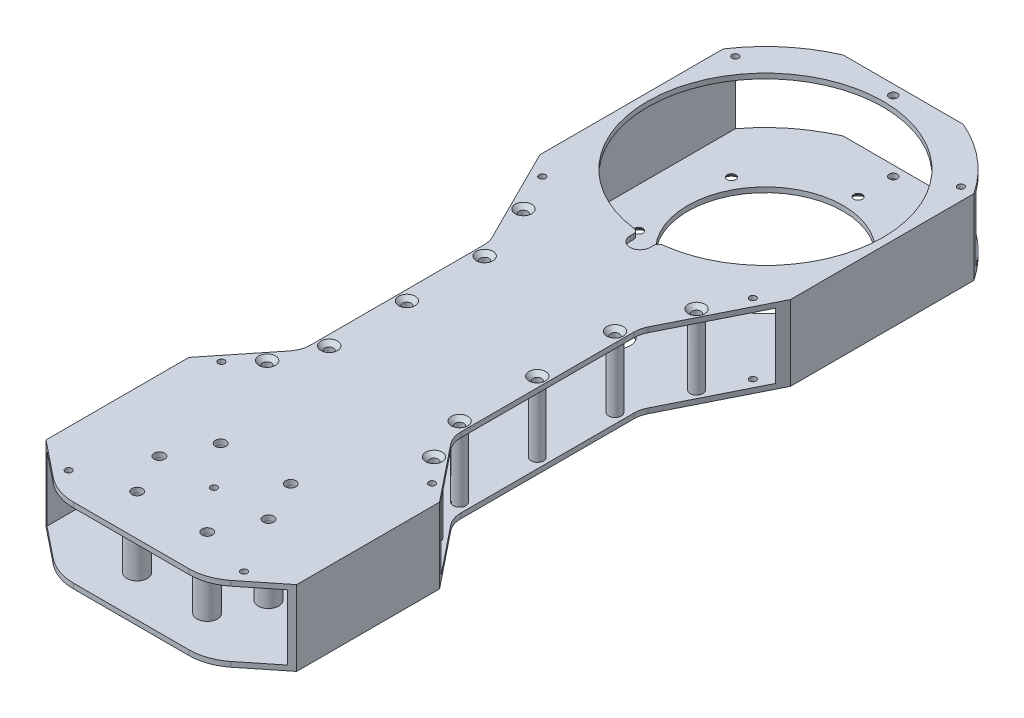
from build123d import *

# Parameters (mm, degrees)
SKETCH_1_W                   = 100
SKETCH_1_H                   = 30
SKETCH_1_W_2                 = 96
SKETCH_1_H_2                 = 26
EXTRUDE_1_DEPTH              = 315
CUT_EXTRUDE_1_REACH          = 32
SKETCH_2_R                   = 5
CUT_EXTRUDE_2_REACH          = 32
SKETCH_3_R                   = 47
SKETCH_8_R                   = 2.1
CUT_EXTRUDE_7_DEPTH          = 31
CUT_EXTRUDE_8_REACH          = 32
SKETCH_9_R                   = 1.6
CUT_EXTRUDE_4_DEPTH          = 31
CUT_EXTRUDE_5_DEPTH          = 31
FILLET_1_R                   = 10
SKETCH_10_R                  = 1.6
CUT_EXTRUDE_9_DEPTH          = 31
SKETCH_11_R                  = 2.5
EXTRUDE_2_DEPTH              = 26
SKETCH_13_R                  = 31
CUT_EXTRUDE_11_DEPTH         = 31
HOLE_WIZARD_M3_1_D           = 3.4
HOLE_WIZARD_M3_1_DEPTH       = 7.5
HOLE_WIZARD_M3_1_CSINK_D     = 6.6
HOLE_WIZARD_M3_1_CSINK_ANGLE = 90
HOLE_WIZARD_M3_1_TIP         = 1.021463052
SKETCH_16_R                  = 6
CUT_EXTRUDE_12_DEPTH         = 2
CUT_EXTRUDE_13_DEPTH         = 2
FILLET_2_R                   = 2
SKETCH_19_R                  = 1.3
CUT_EXTRUDE_15_DEPTH         = 31
CUT_EXTRUDE_18_DEPTH         = 31
FILLET_5_R                   = 20
HOLE_WIZARD_M3_2_D           = 3.4
HOLE_WIZARD_M3_2_DEPTH       = 28
HOLE_WIZARD_M3_2_CSINK_D     = 6.6
HOLE_WIZARD_M3_2_CSINK_ANGLE = 90
SKETCH_24_R                  = 1.3
CUT_EXTRUDE_19_DEPTH         = 10
HOLE_WIZARD_M3_3_D           = 3.4
HOLE_WIZARD_M3_3_DEPTH       = 7.5
HOLE_WIZARD_M3_3_CSINK_D     = 6.6
HOLE_WIZARD_M3_3_CSINK_ANGLE = 90
HOLE_WIZARD_M3_3_TIP         = 1.021463052
SKETCH_27_R                  = 4.1
SKETCH_27_R_2                = 2.2
EXTRUDE_3_DEPTH              = 26
SKETCH_28_R                  = 1.3
CUT_EXTRUDE_20_DEPTH         = 2
SKETCH_31_R                  = 1.65
CUT_EXTRUDE_21_DEPTH         = 31


with BuildPart() as part:
    # 草图1 → 凸台-拉伸1 (new body)
    with BuildSketch(Plane.XY):
        Rectangle(SKETCH_1_W, SKETCH_1_H)
        Rectangle(SKETCH_1_W_2, SKETCH_1_H_2, mode=Mode.SUBTRACT)
    extrude(amount=EXTRUDE_1_DEPTH)

    # 草图2 → 切除-拉伸1 (cut, up to next)
    with BuildSketch(Plane.XZ.offset(15), mode=Mode.PRIVATE) as cut_extrude_1_sk1:
        with Locations((0, 275)):
            Circle(SKETCH_2_R)
    cut_extrude_1_tool1 = extrude(cut_extrude_1_sk1.sketch, amount=-CUT_EXTRUDE_1_REACH, mode=Mode.PRIVATE) & part.part
    add(cut_extrude_1_tool1.solids().sort_by_distance((0, -15, 275))[0], mode=Mode.SUBTRACT)

    # 草图3 → 切除-拉伸2 (cut, up to next)
    with BuildSketch(Plane(origin=(0, 15, 0), x_dir=(1, 0, 0), z_dir=(0, 1, 0)), mode=Mode.PRIVATE) as cut_extrude_2_sk1:
        with Locations((0, -55)):
            Circle(SKETCH_3_R)
    cut_extrude_2_tool1 = extrude(cut_extrude_2_sk1.sketch, amount=-CUT_EXTRUDE_2_REACH, mode=Mode.PRIVATE) & part.part
    add(cut_extrude_2_tool1.solids().sort_by_distance((0, 15, 55))[0], mode=Mode.SUBTRACT)

    # 草图8 → 切除-拉伸7 (cut, through all)
    with BuildSketch(Plane.XZ.offset(15)):
        with Locations((-13.980630511, 291.661466638)):
            Circle(SKETCH_8_R)
        with Locations((13.980630511, 291.661466638)):
            Circle(SKETCH_8_R)
        with Locations((13.980630511, 258.338533362)):
            Circle(SKETCH_8_R)
        with Locations((-13.980630511, 258.338533362)):
            Circle(SKETCH_8_R)
        with Locations((-21.75, 275)):
            Circle(SKETCH_8_R)
        with Locations((21.75, 275)):
            Circle(SKETCH_8_R)
    extrude(amount=-CUT_EXTRUDE_7_DEPTH, mode=Mode.SUBTRACT)

    # 草图9 → 切除-拉伸8 (cut, up to next)
    with BuildSketch(Plane.XZ.offset(15), mode=Mode.PRIVATE) as cut_extrude_8_sk1:
        with Locations((-32.04293994, 73.5)):
            Circle(SKETCH_9_R)
    cut_extrude_8_tool1 = extrude(cut_extrude_8_sk1.sketch, amount=-CUT_EXTRUDE_8_REACH, mode=Mode.PRIVATE) & part.part
    add(cut_extrude_8_tool1.solids().sort_by_distance((-32.04294, -15, 73.5))[0], mode=Mode.SUBTRACT)
    # 草图9 → 切除-拉伸8 (cut, up to next)
    with BuildSketch(Plane.XZ.offset(15), mode=Mode.PRIVATE) as cut_extrude_8_sk2:
        with Locations((0, 92)):
            Circle(SKETCH_9_R)
    cut_extrude_8_tool2 = extrude(cut_extrude_8_sk2.sketch, amount=-CUT_EXTRUDE_8_REACH, mode=Mode.PRIVATE) & part.part
    add(cut_extrude_8_tool2.solids().sort_by_distance((0, -15, 92))[0], mode=Mode.SUBTRACT)
    # 草图9 → 切除-拉伸8 (cut, up to next)
    with BuildSketch(Plane.XZ.offset(15), mode=Mode.PRIVATE) as cut_extrude_8_sk3:
        with Locations((32.04293994, 73.5)):
            Circle(SKETCH_9_R)
    cut_extrude_8_tool3 = extrude(cut_extrude_8_sk3.sketch, amount=-CUT_EXTRUDE_8_REACH, mode=Mode.PRIVATE) & part.part
    add(cut_extrude_8_tool3.solids().sort_by_distance((32.04294, -15, 73.5))[0], mode=Mode.SUBTRACT)
    # 草图9 → 切除-拉伸8 (cut, up to next)
    with BuildSketch(Plane.XZ.offset(15), mode=Mode.PRIVATE) as cut_extrude_8_sk4:
        with Locations((32.04293994, 36.5)):
            Circle(SKETCH_9_R)
    cut_extrude_8_tool4 = extrude(cut_extrude_8_sk4.sketch, amount=-CUT_EXTRUDE_8_REACH, mode=Mode.PRIVATE) & part.part
    add(cut_extrude_8_tool4.solids().sort_by_distance((32.04294, -15, 36.5))[0], mode=Mode.SUBTRACT)
    # 草图9 → 切除-拉伸8 (cut, up to next)
    with BuildSketch(Plane.XZ.offset(15), mode=Mode.PRIVATE) as cut_extrude_8_sk5:
        with Locations((0, 18)):
            Circle(SKETCH_9_R)
    cut_extrude_8_tool5 = extrude(cut_extrude_8_sk5.sketch, amount=-CUT_EXTRUDE_8_REACH, mode=Mode.PRIVATE) & part.part
    add(cut_extrude_8_tool5.solids().sort_by_distance((0, -15, 18))[0], mode=Mode.SUBTRACT)
    # 草图9 → 切除-拉伸8 (cut, up to next)
    with BuildSketch(Plane.XZ.offset(15), mode=Mode.PRIVATE) as cut_extrude_8_sk6:
        with Locations((-32.04293994, 36.5)):
            Circle(SKETCH_9_R)
    cut_extrude_8_tool6 = extrude(cut_extrude_8_sk6.sketch, amount=-CUT_EXTRUDE_8_REACH, mode=Mode.PRIVATE) & part.part
    add(cut_extrude_8_tool6.solids().sort_by_distance((-32.04294, -15, 36.5))[0], mode=Mode.SUBTRACT)

    # 草图5 → 切除-拉伸4 (cut, through all)
    with BuildSketch(Plane(origin=(0, 15, 0), x_dir=(1, 0, 0), z_dir=(0, 1, 0))):
        Polygon((-50, -95), (-30, -135), (-30, -210), (-50, -235), align=None)
        Polygon((50, -95), (50, -235), (30, -210), (30, -135), align=None)
    extrude(amount=-CUT_EXTRUDE_4_DEPTH, mode=Mode.SUBTRACT)

    # 草图6 → 切除-拉伸5 (cut, through all)
    with BuildSketch(Plane(origin=(0, 15, 0), x_dir=(1, 0, 0), z_dir=(0, 1, 0))):
        with BuildLine():
            ThreePointArc((-50, -21.833752096), (-38.566917469, -9.037048866), (-23.979157617, 0))
            Line((-23.979157617, 0), (-50, 0))
            Line((-50, 0), (-50, -21.833752096))
        make_face()
        with BuildLine():
            Line((50, 0), (23.979157617, 0))
            ThreePointArc((23.979157617, 0), (38.566917469, -9.037048866), (50, -21.833752096))
            Line((50, -21.833752096), (50, 0))
        make_face()
    extrude(amount=-CUT_EXTRUDE_5_DEPTH, mode=Mode.SUBTRACT)

    # 圆角1
    fillet_1_edges = [part.edges().sort_by_distance(p)[0] for p in [
        (-30, 14, 135),
        (-30, -14, 135),
        (-30, 14, 210),
        (-30, -14, 210),
        (30, 14, 210),
        (30, 14, 135),
        (30, -14, 135),
        (30, -14, 210),
    ]]
    fillet(fillet_1_edges, radius=FILLET_1_R)

    # 草图10 → 切除-拉伸9 (cut, through all)
    with BuildSketch(Plane(origin=(0, 15, 0), x_dir=(1, 0, 0), z_dir=(0, 1, 0))):
        with Locations((-26, -141)):
            Circle(SKETCH_10_R)
        with Locations((-26, -203)):
            Circle(SKETCH_10_R)
        with Locations((26, -203)):
            Circle(SKETCH_10_R)
        with Locations((26, -141)):
            Circle(SKETCH_10_R)
        with Locations((-26, -172)):
            Circle(SKETCH_10_R)
        with Locations((26, -172)):
            Circle(SKETCH_10_R)
        with Locations((-34.527864045, -117)):
            Circle(SKETCH_10_R)
        with Locations((-33.27750061, -220.5)):
            Circle(SKETCH_10_R)
        with Locations((33.27750061, -220.5)):
            Circle(SKETCH_10_R)
        with Locations((34.527864045, -117)):
            Circle(SKETCH_10_R)
    extrude(amount=-CUT_EXTRUDE_9_DEPTH, mode=Mode.SUBTRACT)

    # 草图11 → 凸台-拉伸2 (add)
    with BuildSketch(Plane(origin=(0, -13, 0), x_dir=(1, 0, 0), z_dir=(0, 1, 0))):
        with Locations((-26, -141)):
            Circle(SKETCH_11_R)
        with Locations((-26, -203)):
            Circle(SKETCH_11_R)
        with Locations((26, -203)):
            Circle(SKETCH_11_R)
        with Locations((26, -141)):
            Circle(SKETCH_11_R)
        with Locations((-26, -172)):
            Circle(SKETCH_11_R)
        with Locations((26, -172)):
            Circle(SKETCH_11_R)
        with Locations((-33.27750061, -220.5)):
            Circle(SKETCH_11_R)
        with Locations((33.27750061, -220.5)):
            Circle(SKETCH_11_R)
        with Locations((-34.527864045, -117)):
            Circle(SKETCH_11_R)
        with Locations((34.527864045, -117)):
            Circle(SKETCH_11_R)
    extrude(amount=EXTRUDE_2_DEPTH)

    # 草图13 → 切除-拉伸11 (cut, through all)
    with BuildSketch(Plane.XZ.offset(15)):
        with Locations((0, 55)):
            Circle(SKETCH_13_R)
    extrude(amount=-CUT_EXTRUDE_11_DEPTH, mode=Mode.SUBTRACT)

    # M3 十字槽沉头木螺钉的锥形沉头孔1
    with Locations(Plane(origin=(0, -15, 92), x_dir=(0, 0, -1), z_dir=(0, -1, 0))):
        with Locations((0, 0), (18.5, 32.04293994), (55.5, 32.04293994), (74, 0), (55.5, -32.04293994), (18.5, -32.04293994)):
            CounterSinkHole(HOLE_WIZARD_M3_1_D / 2, HOLE_WIZARD_M3_1_CSINK_D / 2, depth=HOLE_WIZARD_M3_1_DEPTH, counter_sink_angle=HOLE_WIZARD_M3_1_CSINK_ANGLE)
            with Locations((0, 0, -(HOLE_WIZARD_M3_1_DEPTH + HOLE_WIZARD_M3_1_TIP / 2))):  # 118° drill point
                Cone(0, HOLE_WIZARD_M3_1_D / 2, HOLE_WIZARD_M3_1_TIP, mode=Mode.SUBTRACT)

    # 草图16 → 切除-拉伸12 (cut)
    with BuildSketch(Plane.XZ.offset(15)):
        with Locations((0, 115)):
            Circle(SKETCH_16_R)
    extrude(amount=-CUT_EXTRUDE_12_DEPTH, mode=Mode.SUBTRACT)

    # 草图17 → 切除-拉伸13 (cut)
    with BuildSketch(Plane(origin=(0, 15, 0), x_dir=(1, 0, 0), z_dir=(0, 1, 0))):
        with BuildLine():
            Line((-4, -105), (-4, -101.829477896))
            ThreePointArc((-4, -101.829477896), (0, -102), (4, -101.829477896))
            Line((4, -101.829477896), (4, -105))
            ThreePointArc((4, -105), (0, -109), (-4, -105))
        make_face()
    extrude(amount=-CUT_EXTRUDE_13_DEPTH, mode=Mode.SUBTRACT)

    # 圆角2
    fillet_2_edges = [part.edges().sort_by_distance(p)[0] for p in [
        (4, 14, 101.829477896),
        (-4, 14, 101.829477896),
    ]]
    fillet(fillet_2_edges, radius=FILLET_2_R)

    # 草图19 → 切除-拉伸15 (cut, through all)
    with BuildSketch(Plane(origin=(0, 15, 0), x_dir=(1, 0, 0), z_dir=(0, 1, 0))):
        with Locations((-42, -102)):
            Circle(SKETCH_19_R)
        with Locations((-42, -230)):
            Circle(SKETCH_19_R)
        with Locations((42, -230)):
            Circle(SKETCH_19_R)
        with Locations((42, -102)):
            Circle(SKETCH_19_R)
    extrude(amount=-CUT_EXTRUDE_15_DEPTH, mode=Mode.SUBTRACT)

    # 草图22 → 切除-拉伸18 (cut, through all)
    with BuildSketch(Plane.XZ.offset(15)):
        Polygon((-50, 292), (-30, 308), (30, 308), (50, 292), (50, 315), (-50, 315), align=None)
    extrude(amount=-CUT_EXTRUDE_18_DEPTH, mode=Mode.SUBTRACT)

    # 圆角5
    fillet_5_edges = [part.edges().sort_by_distance(p)[0] for p in [
        (30, 14, 308),
        (30, -14, 308),
        (-30, -14, 308),
        (-30, 14, 308),
    ]]
    fillet(fillet_5_edges, radius=FILLET_5_R)

    # M3 十字槽沉头木螺钉的锥形沉头孔2
    with Locations(Plane(origin=(-33.27750061, -15, 220.5), x_dir=(0, 0, -1), z_dir=(0, -1, 0))):
        with Locations((0, 0), (17.5, 7.27750061), (103.5, -1.250363435), (0, 66.55500122), (103.5, 67.805364655), (79.5, 59.27750061), (48.5, 59.27750061), (17.5, 59.27750061), (48.5, 7.27750061), (79.5, 7.27750061)):
            CounterSinkHole(HOLE_WIZARD_M3_2_D / 2, HOLE_WIZARD_M3_2_CSINK_D / 2, depth=HOLE_WIZARD_M3_2_DEPTH, counter_sink_angle=HOLE_WIZARD_M3_2_CSINK_ANGLE)

    # 草图24 → 切除-拉伸19 (cut)
    with BuildSketch(Plane(origin=(0, 15, 0), x_dir=(1, 0, 0), z_dir=(0, 1, 0))):
        with Locations((-45, -22)):
            Circle(SKETCH_24_R)
        with Locations((45, -22)):
            Circle(SKETCH_24_R)
    extrude(amount=-CUT_EXTRUDE_19_DEPTH, mode=Mode.SUBTRACT)

    # M3 十字槽沉头木螺钉的锥形沉头孔3
    with Locations(Plane(origin=(0, 15, 0), x_dir=(1, 0, 0), z_dir=(0, 1, 0))):
        with Locations((-34.527864045, -117), (-26, -141), (-26, -172), (-26, -203), (-33.27750061, -220.5), (33.27750061, -220.5), (26, -203), (26, -172), (26, -141), (34.527864045, -117)):
            CounterSinkHole(HOLE_WIZARD_M3_3_D / 2, HOLE_WIZARD_M3_3_CSINK_D / 2, depth=HOLE_WIZARD_M3_3_DEPTH, counter_sink_angle=HOLE_WIZARD_M3_3_CSINK_ANGLE)
            with Locations((0, 0, -(HOLE_WIZARD_M3_3_DEPTH + HOLE_WIZARD_M3_3_TIP / 2))):  # 118° drill point
                Cone(0, HOLE_WIZARD_M3_3_D / 2, HOLE_WIZARD_M3_3_TIP, mode=Mode.SUBTRACT)

    # 草图27 → 凸台-拉伸3 (add)
    with BuildSketch(Plane(origin=(0, -13, 0), x_dir=(1, 0, 0), z_dir=(0, 1, 0))):
        with Locations((-13.980630511, -258.338533362)):
            Circle(SKETCH_27_R)
        with Locations((-13.980630511, -258.338533362)):
            Circle(SKETCH_27_R_2, mode=Mode.SUBTRACT)
        with Locations((13.980630511, -258.338533362)):
            Circle(SKETCH_27_R)
        with Locations((13.980630511, -258.338533362)):
            Circle(SKETCH_27_R_2, mode=Mode.SUBTRACT)
        with Locations((21.75, -275)):
            Circle(SKETCH_27_R)
        with Locations((21.75, -275)):
            Circle(SKETCH_27_R_2, mode=Mode.SUBTRACT)
        with Locations((13.980630511, -291.661466638)):
            Circle(SKETCH_27_R)
        with Locations((13.980630511, -291.661466638)):
            Circle(SKETCH_27_R_2, mode=Mode.SUBTRACT)
        with Locations((-13.980630511, -291.661466638)):
            Circle(SKETCH_27_R)
        with Locations((-13.980630511, -291.661466638)):
            Circle(SKETCH_27_R_2, mode=Mode.SUBTRACT)
        with Locations((-21.75, -275)):
            Circle(SKETCH_27_R)
        with Locations((-21.75, -275)):
            Circle(SKETCH_27_R_2, mode=Mode.SUBTRACT)
    extrude(amount=EXTRUDE_3_DEPTH)

    # 草图28 → 切除-拉伸20 (cut)
    with BuildSketch(Plane(origin=(0, 15, 0), x_dir=(1, 0, 0), z_dir=(0, 1, 0))):
        with Locations((-35, -298)):
            Circle(SKETCH_28_R)
        with Locations((35, -298)):
            Circle(SKETCH_28_R)
        with Locations((0, -275)):
            Circle(SKETCH_28_R)
    extrude(amount=-CUT_EXTRUDE_20_DEPTH, mode=Mode.SUBTRACT)

    # 草图31 → 切除-拉伸21 (cut, through all)
    with BuildSketch(Plane(origin=(0, 15, 0), x_dir=(1, 0, 0), z_dir=(0, 1, 0))):
        with Locations((0, -4)):
            Circle(SKETCH_31_R)
    extrude(amount=-CUT_EXTRUDE_21_DEPTH, mode=Mode.SUBTRACT)


solid = part.part
